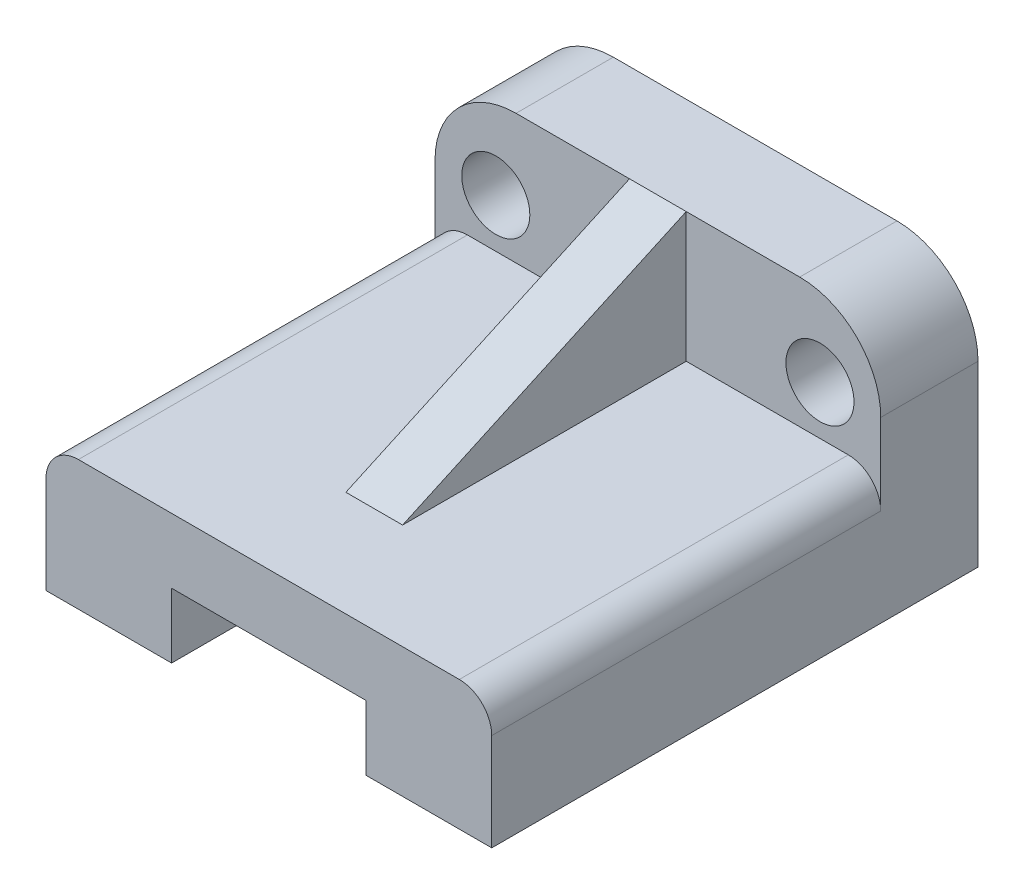
from build123d import *

# Parameters (mm, degrees)
IZIM1_R                     = 4.2
Y_KSEKLIK_EKSTR_ZYON1_DEPTH = 12
Y_KSEKLIK_EKSTR_ZYON2_DEPTH = 48
Y_KSEKLIK_EKSTR_ZYON3_DEPTH = 3.5


with BuildPart() as part:
    # Çizim1 → Yükseklik-Ekstrüzyon1 (new body)
    with BuildSketch(Plane.XY):
        with BuildLine():
            Line((-17.5, 16), (17.5, 16))
            ThreePointArc((17.5, 16), (24.571067812, 13.071067812), (27.5, 6))
            Line((27.5, 6), (27.5, -16))
            Line((27.5, -16), (-27.5, -16))
            Line((-27.5, -16), (-27.5, 6))
            ThreePointArc((-27.5, 6), (-24.571067812, 13.071067812), (-17.5, 16))
        make_face()
        with Locations((-20, 6)):
            Circle(IZIM1_R, mode=Mode.SUBTRACT)
        with Locations((20, 6)):
            Circle(IZIM1_R, mode=Mode.SUBTRACT)
    extrude(amount=Y_KSEKLIK_EKSTR_ZYON1_DEPTH)

    # Çizim2 → Yükseklik-Ekstrüzyon2 (add)
    with BuildSketch(Plane.XY.offset(12)):
        with BuildLine():
            Line((-27.5, -16), (-12, -16))
            Line((-12, -16), (-12, -8))
            Line((-12, -8), (12, -8))
            Line((12, -8), (12, -16))
            Line((12, -16), (27.5, -16))
            Line((27.5, -16), (27.5, -4))
            ThreePointArc((27.5, -4), (26.328427125, -1.171572875), (23.5, 0))
            Line((23.5, 0), (-23.5, 0))
            ThreePointArc((-23.5, 0), (-26.328427125, -1.171572875), (-27.5, -4))
            Line((-27.5, -4), (-27.5, -16))
        make_face()
    extrude(amount=Y_KSEKLIK_EKSTR_ZYON2_DEPTH)

    # Çizim3 → Yükseklik-Ekstrüzyon3 (add, symmetric)
    with BuildSketch(Plane(origin=(0, 0, 0), x_dir=(0, 0, -1), z_dir=(1, 0, 0))):
        Polygon((-12, 16), (-47, 0), (-12, 0), align=None)
    extrude(amount=Y_KSEKLIK_EKSTR_ZYON3_DEPTH, both=True)


solid = part.part
